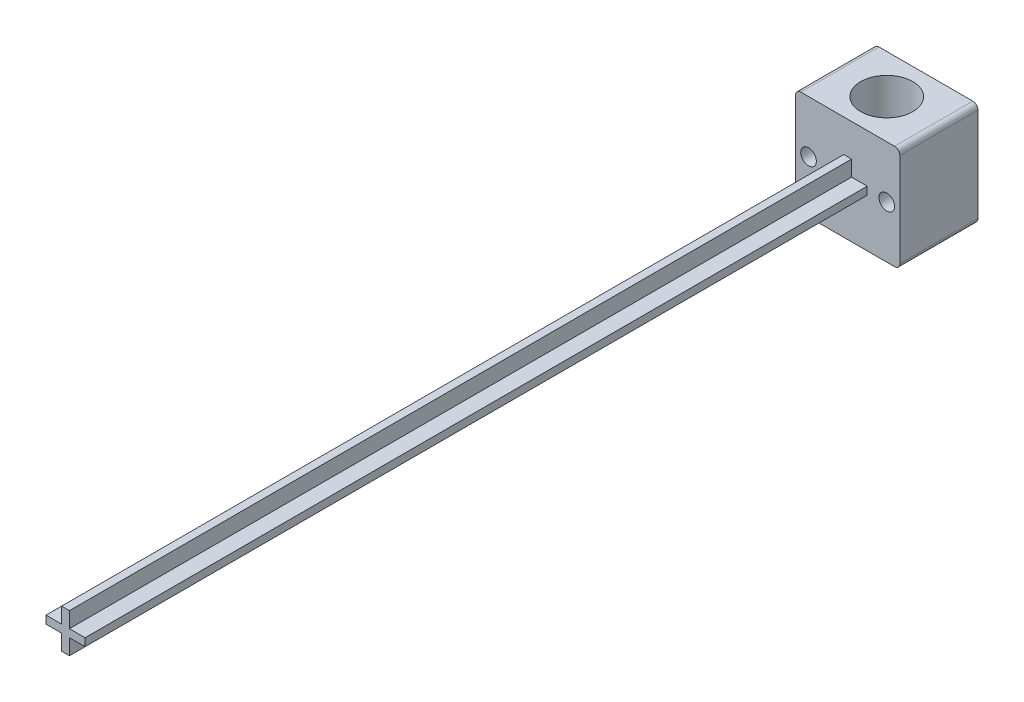
from build123d import *

# Parameters (mm, degrees)
SKETCH1_W           = 20
SKETCH1_H           = 15
SKETCH1_R           = 5
BOSS_EXTRUDE1_DEPTH = 20
SKETCH2_R           = 1.5
CUT_EXTRUDE2_DEPTH  = 20
SKETCH4_W           = 1.5
SKETCH4_H           = 7.5
SKETCH4_W_2         = 7.5
SKETCH4_H_2         = 1.5
BOSS_EXTRUDE3_DEPTH = 150
FILLET3_R           = 1


with BuildPart() as part:
    # Sketch1 → Boss-Extrude1 (new body)
    with BuildSketch(Plane(origin=(0, 0, 0), x_dir=(1, 0, 0), z_dir=(0, 1, 0))):
        Rectangle(SKETCH1_W, SKETCH1_H)
        Circle(SKETCH1_R, mode=Mode.SUBTRACT)
    extrude(amount=BOSS_EXTRUDE1_DEPTH)

    # Sketch2 → Cut-Extrude2 (cut)
    with BuildSketch(Plane.XY.offset(7.5)):
        with Locations((7.5, 10)):
            Circle(SKETCH2_R)
        with Locations((-7.5, 10)):
            Circle(SKETCH2_R)
    extrude(amount=-CUT_EXTRUDE2_DEPTH, mode=Mode.SUBTRACT)

    # Sketch4 → Boss-Extrude3 (add)
    with BuildSketch(Plane.XY.offset(7.5)):
        with Locations((0, 10)):
            Rectangle(SKETCH4_W, SKETCH4_H)
        with Locations((0, 10)):
            Rectangle(SKETCH4_W_2, SKETCH4_H_2)
    extrude(amount=BOSS_EXTRUDE3_DEPTH)

    # Fillet3
    fillet3_edges = [part.edges().sort_by_distance(p)[0] for p in [
        (-10, 20, 0),
        (10, 20, 0),
        (-10, 0, 0),
        (10, 0, 0),
    ]]
    fillet(fillet3_edges, radius=FILLET3_R)


solid = part.part
